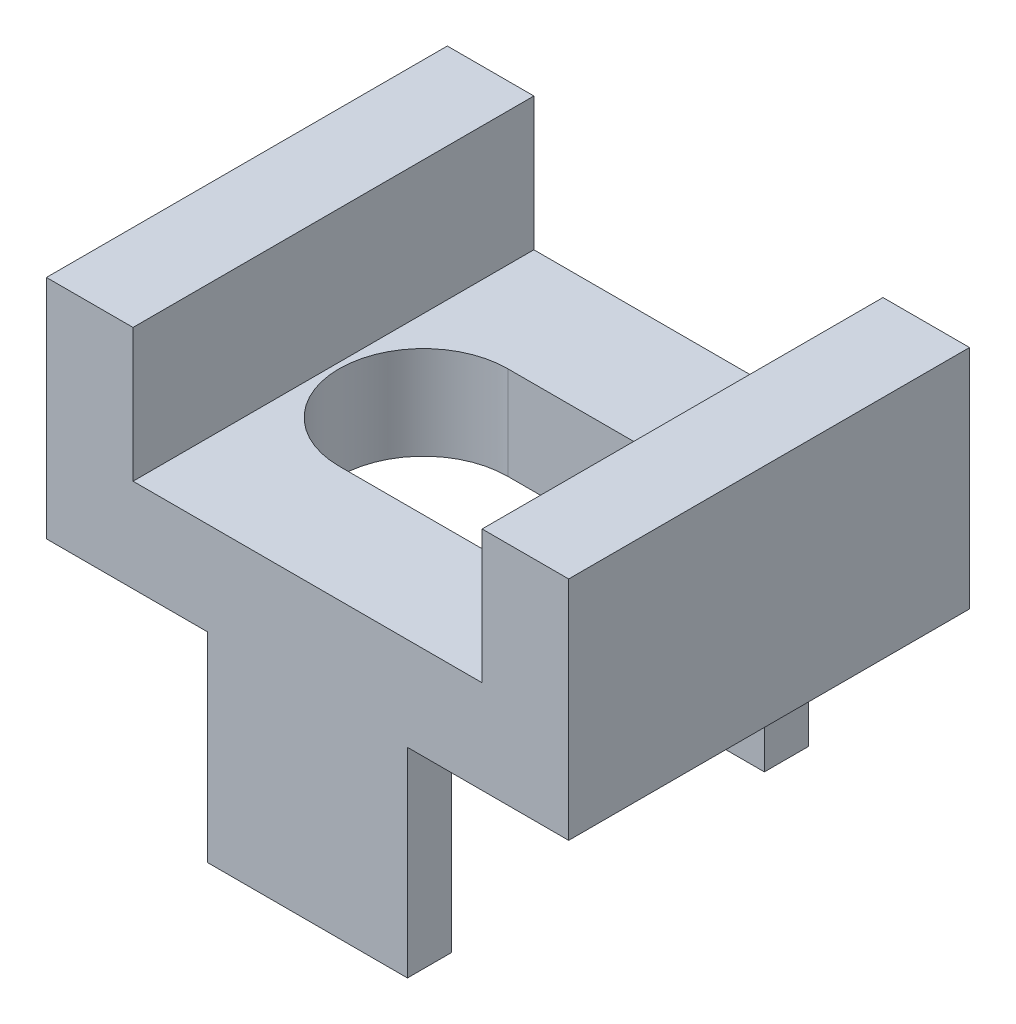
from build123d import *

# Parameters (mm, degrees)
SKETCH1_W               = 3.0098
SKETCH1_H               = 3.921
BOSS_EXTRUDE1_DEPTH     = 0.7
SKETCH4_W               = 0.33
SKETCH4_H               = 0.75
BOSS_EXTRUDE2_DEPTH     = 1.5
MIRROR9_COPY_1_SKETCH_W = 0.33
MIRROR9_COPY_1_SKETCH_H = 0.75
MIRROR9_COPY_1_DEPTH    = 1.5
SKETCH5_W               = 3.0098
SKETCH5_H               = 0.65
BOSS_EXTRUDE3_DEPTH     = 1


with BuildPart() as part:
    # Sketch1 → Boss-Extrude1 (new body)
    with BuildSketch(Plane.ZX.offset(15.217946538)):
        with Locations((1.764464597, -29.107286197)):
            Rectangle(SKETCH1_W, SKETCH1_H)
        with BuildLine():
            Line((1.131064597, -29.742286197), (1.131064597, -28.472286197))
            ThreePointArc((1.131064597, -28.472286197), (1.764464597, -27.838886197), (2.397864597, -28.472286197))
            Line((2.397864597, -28.472286197), (2.397864597, -29.742286197))
            ThreePointArc((2.397864597, -29.742286197), (1.764464597, -30.375686197), (1.131064597, -29.742286197))
        make_face(mode=Mode.SUBTRACT)
    extrude(amount=BOSS_EXTRUDE1_DEPTH)

    # Sketch4 → Boss-Extrude2 (add)
    with BuildSketch(Plane(origin=(0, 15.217946538, 0), x_dir=(0, 0, -1), z_dir=(0, -1, 0))):
        with Locations((-3.104364597, -28.732286197)):
            Rectangle(SKETCH4_W, SKETCH4_H)
    boss_extrude2 = extrude(amount=BOSS_EXTRUDE2_DEPTH)

    # Mirror8: Boss-Extrude2 across plane
    add(boss_extrude2.mirror(Plane.XY.offset(1.764464597)))

    # Mirror9: Boss-Extrude2 across plane
    add(boss_extrude2.mirror(Plane(origin=(-29.107286197, 13.717946538, 0.589564597), x_dir=(0, 0, 1), z_dir=(1, 0, 0))))

    # Mirror9 copy 1 sketch → Mirror9 copy 1 (add)
    with BuildSketch(Plane(origin=(-58.214572393, 15.217946538, 3.528929194), x_dir=(0, 0, 1), z_dir=(0, -1, 0))):
        with Locations((-3.104364597, -28.732286197)):
            Rectangle(MIRROR9_COPY_1_SKETCH_W, MIRROR9_COPY_1_SKETCH_H)
    extrude(amount=MIRROR9_COPY_1_DEPTH)

    # Sketch5 → Boss-Extrude3 (add)
    with BuildSketch(Plane.ZX.offset(15.917946538)):
        with Locations((1.764464597, -27.471786197)):
            Rectangle(SKETCH5_W, SKETCH5_H)
    boss_extrude3 = extrude(amount=BOSS_EXTRUDE3_DEPTH)

    # Mirror10: Boss-Extrude3 across plane
    add(boss_extrude3.mirror(Plane(origin=(-29.107286197, 0, 0), x_dir=(0, 0, 1), z_dir=(1, 0, 0))))


solid = part.part
